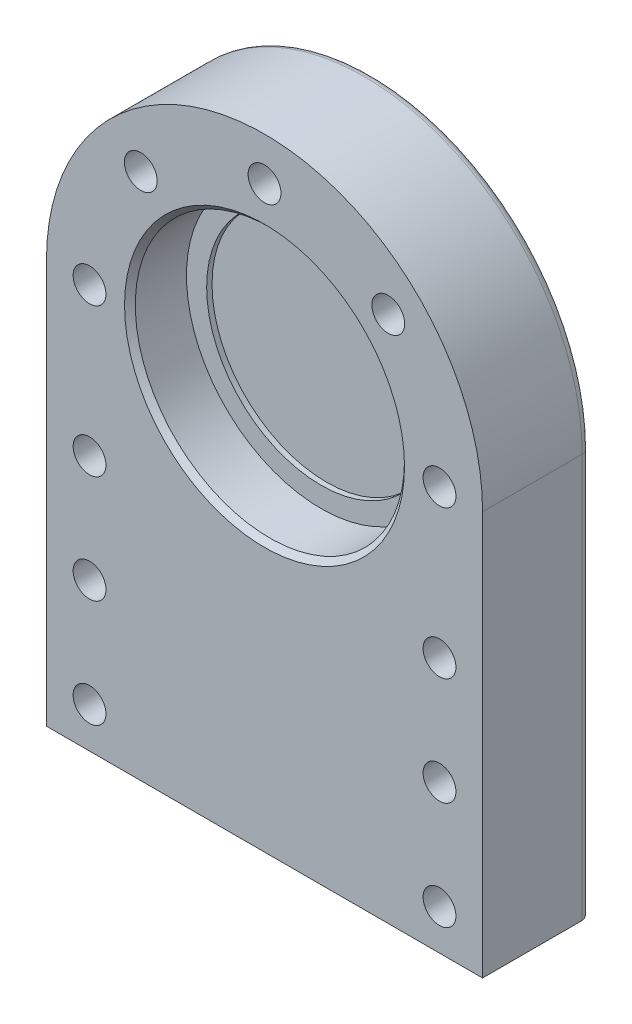
from build123d import *

# Parameters (mm, degrees)
BOSS_EXTRUDE1_DEPTH = 40
SKETCH2_R           = 6.1
CUT_EXTRUDE1_DEPTH  = 40
CIRPATTERN1_COUNT   = 5
CIRPATTERN1_ANGLE   = 180
SKETCH3_R           = 6.1
CUT_EXTRUDE2_DEPTH  = 40
SKETCH5_R           = 50
CUT_EXTRUDE3_DEPTH  = 21
SKETCH6_R           = 42.5
CUT_EXTRUDE4_DEPTH  = 2
CHAMFER1_SIZE       = 2
FILLET1_R           = 3


with BuildPart() as part:
    # Sketch1 → Boss-Extrude1 (new body)
    with BuildSketch(Plane.XY):
        with BuildLine():
            Line((-81, 0), (-81, -150))
            Line((-81, -150), (81, -150))
            Line((81, -150), (81, 0))
            ThreePointArc((81, 0), (0, 81), (-81, 0))
        make_face()
    extrude(amount=BOSS_EXTRUDE1_DEPTH)

    # Sketch2 → Cut-Extrude1 (cut)
    with BuildSketch(Plane.XY.offset(40)):
        with Locations((-65, 0)):
            Circle(SKETCH2_R)
    cut_extrude1 = extrude(amount=-CUT_EXTRUDE1_DEPTH, mode=Mode.SUBTRACT)

    # CirPattern1: Cut-Extrude1 ×5 about axis
    cirpattern1_axis = Axis((0, 0, 0), (0, 0, -1))
    for i in range(1, CIRPATTERN1_COUNT):
        add(cut_extrude1.rotate(cirpattern1_axis, i * CIRPATTERN1_ANGLE / (CIRPATTERN1_COUNT - 1)), mode=Mode.SUBTRACT)

    # Sketch3 → Cut-Extrude2 (cut)
    with BuildSketch(Plane.XY.offset(40)):
        with Locations((-65, -135)):
            Circle(SKETCH3_R)
        with Locations((-65, -95)):
            Circle(SKETCH3_R)
        with Locations((-65, -55)):
            Circle(SKETCH3_R)
    cut_extrude2 = extrude(amount=-CUT_EXTRUDE2_DEPTH, mode=Mode.SUBTRACT)

    # Mirror1: Cut-Extrude2 across plane
    add(cut_extrude2.mirror(Plane(origin=(0, 0, 0), x_dir=(0, 0, 1), z_dir=(1, 0, 0))), mode=Mode.SUBTRACT)

    # Sketch5 → Cut-Extrude3 (cut)
    with BuildSketch(Plane.XY.offset(40)):
        Circle(SKETCH5_R)
    extrude(amount=-CUT_EXTRUDE3_DEPTH, mode=Mode.SUBTRACT)

    # Sketch6 → Cut-Extrude4 (cut)
    with BuildSketch(Plane.XY.offset(19)):
        Circle(SKETCH6_R)
    extrude(amount=-CUT_EXTRUDE4_DEPTH, mode=Mode.SUBTRACT)

    # Chamfer1
    chamfer1_edges = [part.edges().sort_by_distance(p)[0] for p in [
        (-50, 0, 40),
    ]]
    chamfer(chamfer1_edges, length=CHAMFER1_SIZE)

    # Fillet1
    fillet1_edges = [part.edges().sort_by_distance(p)[0] for p in [
        (81, -75, 0),
        (0, -150, 0),
        (-81, -75, 0),
        (0, 81, 0),
    ]]
    fillet(fillet1_edges, radius=FILLET1_R)


solid = part.part
